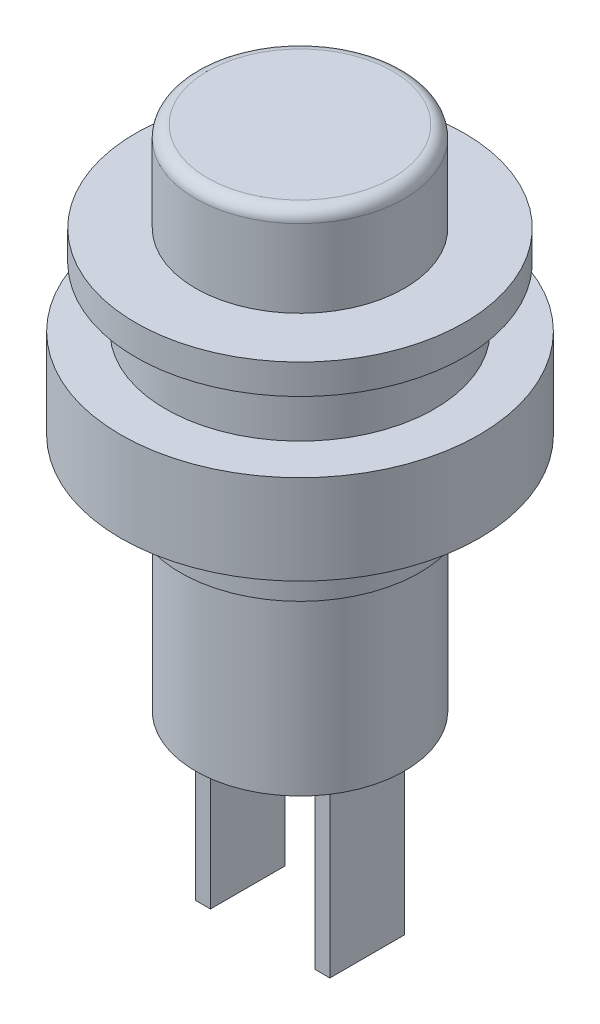
from build123d import *

# Parameters (mm, degrees)
SKETCH1_R           = 3.5
BOSS_EXTRUDE1_DEPTH = 3
FILLET1_R           = 0.4
SKETCH2_R           = 5.5
SKETCH2_R_2         = 3.5
BOSS_EXTRUDE2_DEPTH = 1
SKETCH3_R           = 4.5
BOSS_EXTRUDE3_DEPTH = 2
SKETCH4_R           = 6
SKETCH4_R_2         = 4.5
BOSS_EXTRUDE4_DEPTH = 3
SKETCH5_R           = 4
BOSS_EXTRUDE5_DEPTH = 2
SKETCH7_R           = 3.5
BOSS_EXTRUDE6_DEPTH = 6
SKETCH8_W           = 0.5
SKETCH8_H           = 2.5
BOSS_EXTRUDE7_DEPTH = 6


with BuildPart() as part:
    # Sketch1 → Boss-Extrude1 (new body)
    with BuildSketch(Plane(origin=(0, 0, 0), x_dir=(1, 0, 0), z_dir=(0, 1, 0))):
        with Locations(Location((0, 0, 0), (0, 0, 270))):
            Circle(SKETCH1_R)
    extrude(amount=BOSS_EXTRUDE1_DEPTH)

    # Fillet1
    fillet1_edges = [part.edges().sort_by_distance(p)[0] for p in [
        (0, 3, -3.5),
    ]]
    fillet(fillet1_edges, radius=FILLET1_R)

    # Sketch2 → Boss-Extrude2 (add)
    with BuildSketch(Plane.XZ):
        with Locations(Location((0, 0, 0), (0, 0, 270))):
            Circle(SKETCH2_R)
        with Locations(Location((0, 0, 0), (0, 0, 90))):
            Circle(SKETCH2_R_2, mode=Mode.SUBTRACT)
        with Locations(Location((0, 0, 0), (0, 0, 90))):
            Circle(SKETCH2_R_2)
    extrude(amount=BOSS_EXTRUDE2_DEPTH)

    # Sketch3 → Boss-Extrude3 (add)
    with BuildSketch(Plane.XZ.offset(1)):
        with Locations(Location((0, 0, 0), (0, 0, 270))):
            Circle(SKETCH3_R)
    extrude(amount=BOSS_EXTRUDE3_DEPTH)

    # Sketch4 → Boss-Extrude4 (add)
    with BuildSketch(Plane.XZ.offset(3)):
        with Locations(Location((0, 0, 0), (0, 0, 270))):
            Circle(SKETCH4_R)
        with Locations(Location((0, 0, 0), (0, 0, 270))):
            Circle(SKETCH4_R_2, mode=Mode.SUBTRACT)
        with Locations(Location((0, 0, 0), (0, 0, 270))):
            Circle(SKETCH4_R_2)
    extrude(amount=BOSS_EXTRUDE4_DEPTH)

    # Sketch5 → Boss-Extrude5 (add)
    with BuildSketch(Plane.XZ.offset(6)):
        with Locations(Location((0, 0, 0), (0, 0, 270))):
            Circle(SKETCH5_R)
    extrude(amount=BOSS_EXTRUDE5_DEPTH)

    # Sketch7 → Boss-Extrude6 (add)
    with BuildSketch(Plane.XZ.offset(8)):
        with Locations(Location((0, 0, 0), (0, 0, 90))):
            Circle(SKETCH7_R)
    extrude(amount=BOSS_EXTRUDE6_DEPTH)

    # Sketch8 → Boss-Extrude7 (add)
    with BuildSketch(Plane.XZ.offset(14)):
        with Locations((2, 0)):
            Rectangle(SKETCH8_W, SKETCH8_H)
        with Locations((-2, 0)):
            Rectangle(SKETCH8_W, SKETCH8_H)
    extrude(amount=BOSS_EXTRUDE7_DEPTH)


solid = part.part
